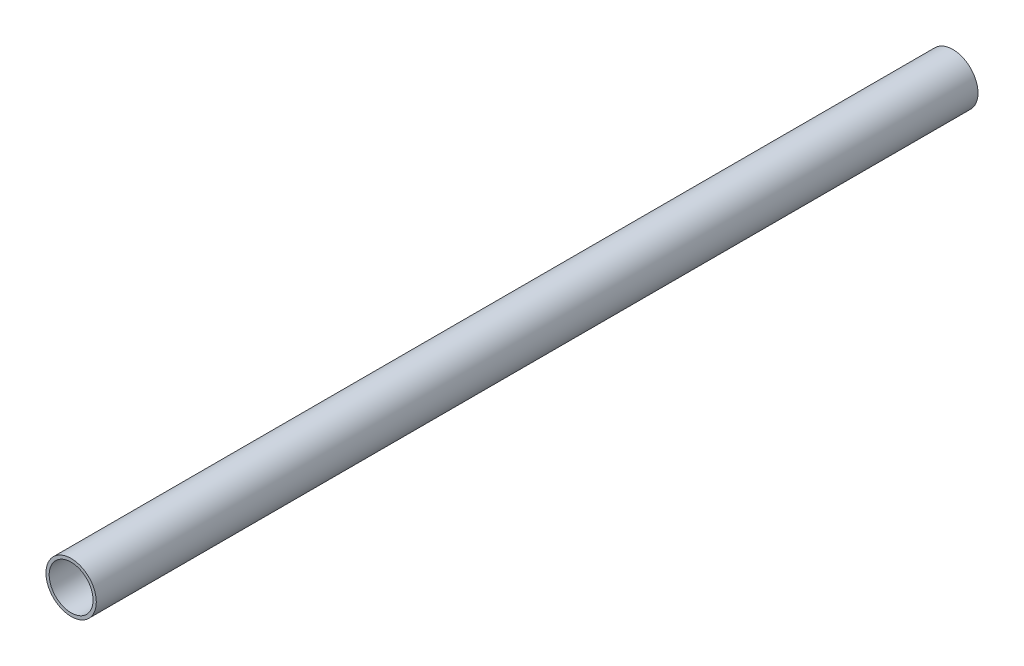
from build123d import *

# Parameters (mm, degrees)
SKETCH2_R           = 6.35
SKETCH2_R_2         = 5.5372
BOSS_EXTRUDE1_DEPTH = 111.1885


with BuildPart() as part:
    # Sketch2 → Boss-Extrude1 (new, symmetric)
    with BuildSketch(Plane.XY):
        Circle(SKETCH2_R)
        Circle(SKETCH2_R_2, mode=Mode.SUBTRACT)
    extrude(amount=BOSS_EXTRUDE1_DEPTH, both=True)


solid = part.part
